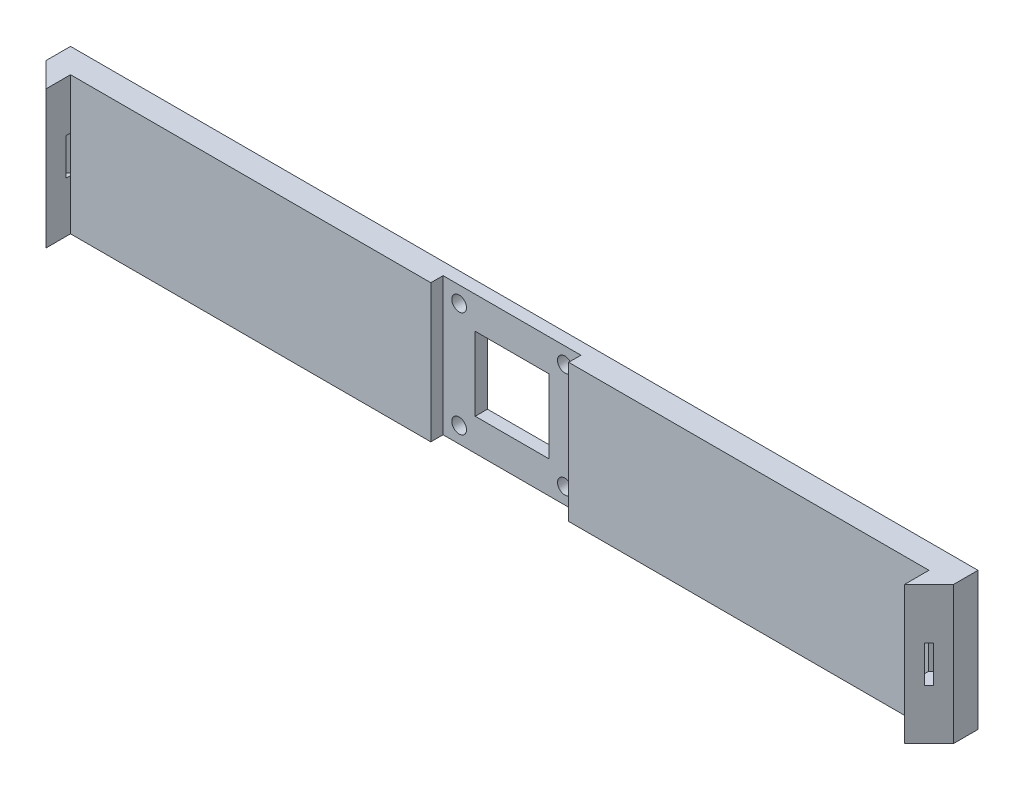
from build123d import *

# Parameters (mm, degrees)
SKETCH1_W           = 350
SKETCH1_H           = 56.2
BOSS_EXTRUDE1_DEPTH = 10
SKETCH2_W           = 56.2
SKETCH2_H           = 56.2
CUT_EXTRUDE1_DEPTH  = 5
SKETCH3_W           = 10
SKETCH3_H           = 56.2
BOSS_EXTRUDE2_DEPTH = 10
SKETCH4_W           = 10
SKETCH4_H           = 56.2
BOSS_EXTRUDE3_DEPTH = 10
CUT_EXTRUDE2_DEPTH  = 56.2
SKETCH6_W           = 10
SKETCH6_H           = 56.2
BOSS_EXTRUDE4_DEPTH = 10
SKETCH7_W           = 10
SKETCH7_H           = 56.2
BOSS_EXTRUDE5_DEPTH = 10
CUT_EXTRUDE3_DEPTH  = 56.2
SKETCH9_W           = 30
SKETCH9_H           = 30
CUT_EXTRUDE4_DEPTH  = 5
SKETCH10_R          = 3
CUT_EXTRUDE5_DEPTH  = 5
SKETCH11_W          = 2.5
SKETCH11_H          = 15
CUT_EXTRUDE6_DEPTH  = 7
SKETCH12_W          = 2.5
SKETCH12_H          = 15
CUT_EXTRUDE7_DEPTH  = 7


with BuildPart() as part:
    # Sketch1 → Boss-Extrude1 (new body)
    with BuildSketch(Plane.XY):
        Rectangle(SKETCH1_W, SKETCH1_H)
    extrude(amount=BOSS_EXTRUDE1_DEPTH)

    # Sketch2 → Cut-Extrude1 (cut)
    with BuildSketch(Plane.XY.offset(10)):
        Rectangle(SKETCH2_W, SKETCH2_H)
    extrude(amount=-CUT_EXTRUDE1_DEPTH, mode=Mode.SUBTRACT)

    # Sketch3 → Boss-Extrude2 (add)
    with BuildSketch(Plane(origin=(175, 0, 0), x_dir=(0, 0, -1), z_dir=(1, 0, 0))):
        with Locations((-5, 0)):
            Rectangle(SKETCH3_W, SKETCH3_H)
    extrude(amount=BOSS_EXTRUDE2_DEPTH)

    # Sketch4 → Boss-Extrude3 (add)
    with BuildSketch(Plane.XY.offset(10)):
        with Locations((180, 0)):
            Rectangle(SKETCH4_W, SKETCH4_H)
    extrude(amount=BOSS_EXTRUDE3_DEPTH)

    # Sketch5 → Cut-Extrude2 (cut)
    with BuildSketch(Plane(origin=(0, 28.1, 0), x_dir=(1, 0, 0), z_dir=(0, 1, 0))):
        Polygon((175, -20), (185, -10), (185, -20), align=None)
    extrude(amount=-CUT_EXTRUDE2_DEPTH, mode=Mode.SUBTRACT)

    # Sketch6 → Boss-Extrude4 (add)
    with BuildSketch(Plane.ZY.offset(175)):
        with Locations((5, 0)):
            Rectangle(SKETCH6_W, SKETCH6_H)
    extrude(amount=BOSS_EXTRUDE4_DEPTH)

    # Sketch7 → Boss-Extrude5 (add)
    with BuildSketch(Plane.XY.offset(10)):
        with Locations((-180, 0)):
            Rectangle(SKETCH7_W, SKETCH7_H)
    extrude(amount=BOSS_EXTRUDE5_DEPTH)

    # Sketch8 → Cut-Extrude3 (cut)
    with BuildSketch(Plane(origin=(0, 28.1, 0), x_dir=(1, 0, 0), z_dir=(0, 1, 0))):
        Polygon((-175, -20), (-185, -10), (-185, -20), align=None)
    extrude(amount=-CUT_EXTRUDE3_DEPTH, mode=Mode.SUBTRACT)

    # Sketch9 → Cut-Extrude4 (cut)
    with BuildSketch(Plane.XY.offset(5)):
        Rectangle(SKETCH9_W, SKETCH9_H)
    extrude(amount=-CUT_EXTRUDE4_DEPTH, mode=Mode.SUBTRACT)

    # Sketch10 → Cut-Extrude5 (cut)
    with BuildSketch(Plane.XY.offset(5)):
        with Locations((21.55, 21.55)):
            Circle(SKETCH10_R)
        with Locations((-21.55, -21.55)):
            Circle(SKETCH10_R)
        with Locations((-21.55, 21.55)):
            Circle(SKETCH10_R)
        with Locations((21.55, -21.55)):
            Circle(SKETCH10_R)
    extrude(amount=-CUT_EXTRUDE5_DEPTH, mode=Mode.SUBTRACT)

    # Sketch11 → Cut-Extrude6 (cut)
    with BuildSketch(Plane(origin=(97.5, 0, 97.5), x_dir=(0.707106781, 0, -0.707106781), z_dir=(0.707106781, 0, 0.707106781))):
        with Locations((116.672618896, 0)):
            Rectangle(SKETCH11_W, SKETCH11_H)
    extrude(amount=-CUT_EXTRUDE6_DEPTH, mode=Mode.SUBTRACT)

    # Sketch12 → Cut-Extrude7 (cut)
    with BuildSketch(Plane(origin=(-97.5, 0, 97.5), x_dir=(0.707106781, 0, 0.707106781), z_dir=(-0.707106781, 0, 0.707106781))):
        with Locations((-116.672618896, 0)):
            Rectangle(SKETCH12_W, SKETCH12_H)
    extrude(amount=-CUT_EXTRUDE7_DEPTH, mode=Mode.SUBTRACT)


solid = part.part
